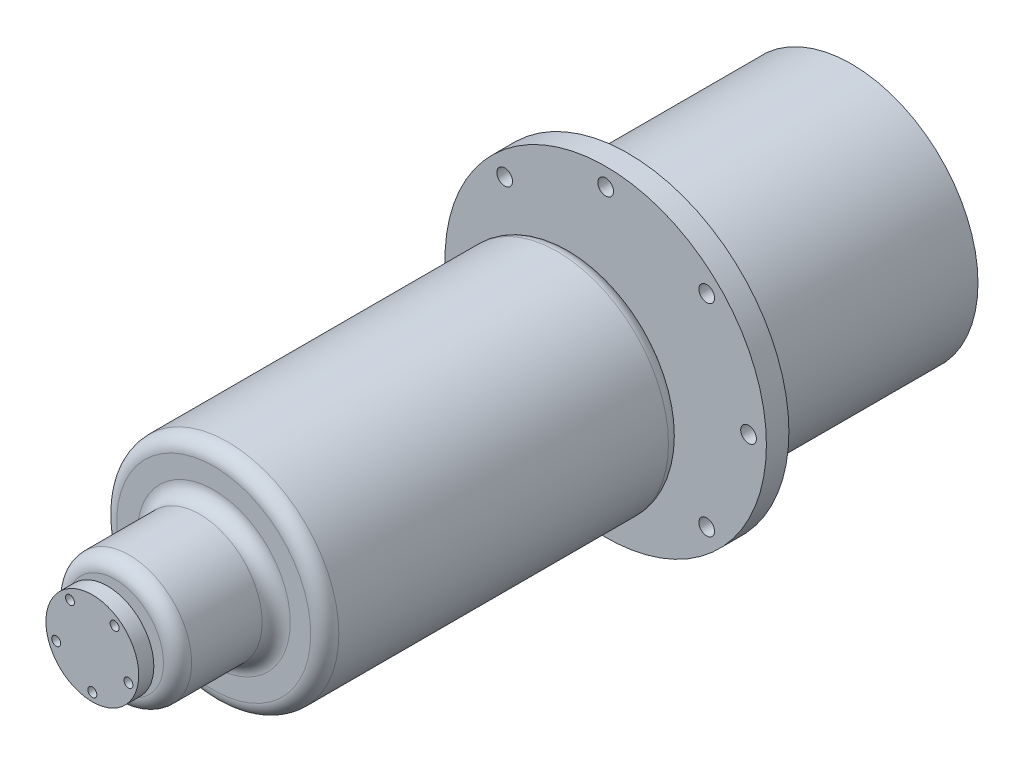
from build123d import *

# Parameters (mm, degrees)
SKETCH1_R          = 57.15
EXTRUDE1_DEPTH     = 4
SKETCH3_R          = 7.5
EXTRUDE2_DEPTH     = 12.166
SKETCH4_R          = 39.5
EXTRUDE3_DEPTH     = 127.24
SKETCH5_R          = 22.225
EXTRUDE4_DEPTH     = 35.083496
SKETCH6_R          = 9.525
EXTRUDE5_DEPTH     = 2.702052
SKETCH7_R          = 16.5
EXTRUDE6_DEPTH     = 5.3848
SKETCH8_R          = 1.6
CUT_EXTRUDE1_DEPTH = 5.3848
SKETCH10_R         = 2.79
CUT_EXTRUDE2_DEPTH = 8
SKETCH11_R         = 45
EXTRUDE7_DEPTH     = 79.4
FILLET1_R          = 5


with BuildPart() as part:
    # Sketch1 → Extrude1 (new body, symmetric)
    with BuildSketch(Plane.XY):
        Circle(SKETCH1_R)
    extrude(amount=EXTRUDE1_DEPTH, both=True)

    # Sketch3 → Extrude2 (add)
    with BuildSketch(Plane.XY.offset(4)):
        Circle(SKETCH3_R)
    extrude(amount=EXTRUDE2_DEPTH)

    # Sketch4 → Extrude3 (add)
    with BuildSketch(Plane.XY.offset(16.166)):
        Circle(SKETCH4_R)
    extrude(amount=EXTRUDE3_DEPTH)

    # Sketch5 → Extrude4 (add)
    with BuildSketch(Plane.XY.offset(143.406)):
        Circle(SKETCH5_R)
    extrude(amount=EXTRUDE4_DEPTH)

    # Sketch6 → Extrude5 (add)
    with BuildSketch(Plane.XY.offset(178.489496)):
        Circle(SKETCH6_R)
    extrude(amount=EXTRUDE5_DEPTH)

    # Sketch7 → Extrude6 (add)
    with BuildSketch(Plane.XY.offset(181.191548)):
        Circle(SKETCH7_R)
    extrude(amount=EXTRUDE6_DEPTH)

    # Sketch8 → Cut-Extrude1 (cut)
    with BuildSketch(Plane.XY.offset(186.576348)):
        with Locations((-7.935100906, 10.921729424)):
            Circle(SKETCH8_R)
        with Locations((7.935100906, 10.921729424)):
            Circle(SKETCH8_R)
        with Locations((12.83926297, -4.171729424)):
            Circle(SKETCH8_R)
        with Locations((0, -13.5)):
            Circle(SKETCH8_R)
        with Locations((-12.83926297, -4.171729424)):
            Circle(SKETCH8_R)
    extrude(amount=-CUT_EXTRUDE1_DEPTH, mode=Mode.SUBTRACT)

    # Sketch10 → Cut-Extrude2 (cut)
    with BuildSketch(Plane(origin=(0, 0, -4), x_dir=(-1, 0, 0), z_dir=(0, 0, -1))):
        with Locations((0, 50.8)):
            Circle(SKETCH10_R)
        with Locations((35.921024484, 35.921024484)):
            Circle(SKETCH10_R)
        with Locations((50.8, 0)):
            Circle(SKETCH10_R)
        with Locations((35.921024484, -35.921024484)):
            Circle(SKETCH10_R)
        with Locations((0, -50.8)):
            Circle(SKETCH10_R)
        with Locations((-35.921024484, -35.921024484)):
            Circle(SKETCH10_R)
        with Locations((-50.8, 0)):
            Circle(SKETCH10_R)
        with Locations((-35.921024484, 35.921024484)):
            Circle(SKETCH10_R)
    extrude(amount=-CUT_EXTRUDE2_DEPTH, mode=Mode.SUBTRACT)

    # Sketch11 → Extrude7 (add)
    with BuildSketch(Plane(origin=(0, 0, -4), x_dir=(-1, 0, 0), z_dir=(0, 0, -1))):
        with Locations(Location((0, 0, 0), (0, 0, 180))):  # turned: the seam where the file's is
            Circle(SKETCH11_R)
    extrude(amount=EXTRUDE7_DEPTH)

    # Fillet1
    fillet1_edges = [part.edges().sort_by_distance(p)[0] for p in [
        (-39.5, 0, 143.406),
        (-22.225, 0, 143.406),
        (-22.225, 0, 178.489496),
        (-39.5, 0, 16.166),
    ]]
    fillet(fillet1_edges, radius=FILLET1_R)


solid = part.part
